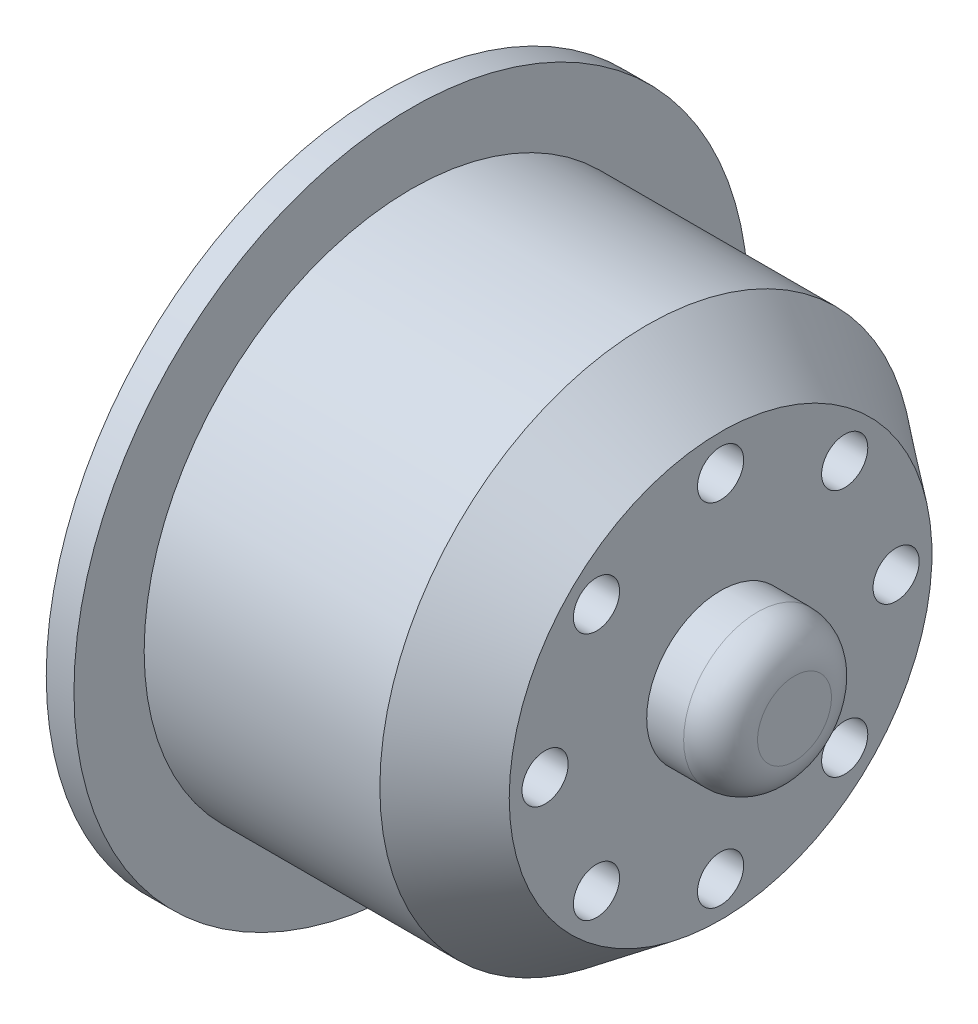
from build123d import *

# Parameters (mm, degrees)
SKETCH2_R          = 1.25
CUT_EXTRUDE1_DEPTH = 19.25
FILLET1_R          = 2
SKETCH3_R          = 2.5
CUT_EXTRUDE2_DEPTH = 13.25
SKETCH4_R          = 11
CUT_EXTRUDE3_DEPTH = 6


with BuildPart() as part:
    # Sketch1 → Revolve1 (revolve)
    with BuildSketch(Plane(origin=(0, 0, 0), x_dir=(1, 0, 0), z_dir=(0, 1, 0))):
        Polygon((-6.130434783, 14.45), (6.626387667, 14.45), (10.619565217, 11.440924884), (10.619565217, 4), (14.619565217, 4), (14.619565217, 0), (13.372742768, 0), (-6.130434783, 0), (-7.630434783, 0), (-7.630434783, 18.25), (-6.130434783, 18.25), align=None)
    revolve(axis=Axis((-12.391304348, 0, 0), (1, 0, 0)))

    # Sketch2 → Cut-Extrude1 (cut, through all)
    with BuildSketch(Plane(origin=(10.619565217, 0, 0), x_dir=(0, 0, -1), z_dir=(1, 0, 0))):
        with Locations((0, 9.5)):
            Circle(SKETCH2_R)
        with Locations((6.717514421, 6.717514421)):
            Circle(SKETCH2_R)
        with Locations((9.5, 0)):
            Circle(SKETCH2_R)
        with Locations((6.717514421, -6.717514421)):
            Circle(SKETCH2_R)
        with Locations((0, -9.5)):
            Circle(SKETCH2_R)
        with Locations((-6.717514421, -6.717514421)):
            Circle(SKETCH2_R)
        with Locations((-9.5, 0)):
            Circle(SKETCH2_R)
        with Locations((-6.717514421, 6.717514421)):
            Circle(SKETCH2_R)
    extrude(amount=-CUT_EXTRUDE1_DEPTH, mode=Mode.SUBTRACT)

    # Fillet1
    fillet1_edges = [part.edges().sort_by_distance(p)[0] for p in [
        (14.619565217, 0, 4),
    ]]
    fillet(fillet1_edges, radius=FILLET1_R)

    # Sketch3 → Cut-Extrude2 (cut)
    with BuildSketch(Plane.ZY.offset(7.630434783)):
        with Locations((0, 9.5)):
            Circle(SKETCH3_R)
        with Locations((6.717514421, 6.717514421)):
            Circle(SKETCH3_R)
        with Locations((9.5, 0)):
            Circle(SKETCH3_R)
        with Locations((6.717514421, -6.717514421)):
            Circle(SKETCH3_R)
        with Locations((0, -9.5)):
            Circle(SKETCH3_R)
        with Locations((-6.717514421, -6.717514421)):
            Circle(SKETCH3_R)
        with Locations((-9.5, 0)):
            Circle(SKETCH3_R)
        with Locations((-6.717514421, 6.717514421)):
            Circle(SKETCH3_R)
    extrude(amount=-CUT_EXTRUDE2_DEPTH, mode=Mode.SUBTRACT)

    # Sketch4 → Cut-Extrude3 (cut)
    with BuildSketch(Plane.ZY.offset(7.630434783)):
        Circle(SKETCH4_R)
    extrude(amount=-CUT_EXTRUDE3_DEPTH, mode=Mode.SUBTRACT)


solid = part.part
